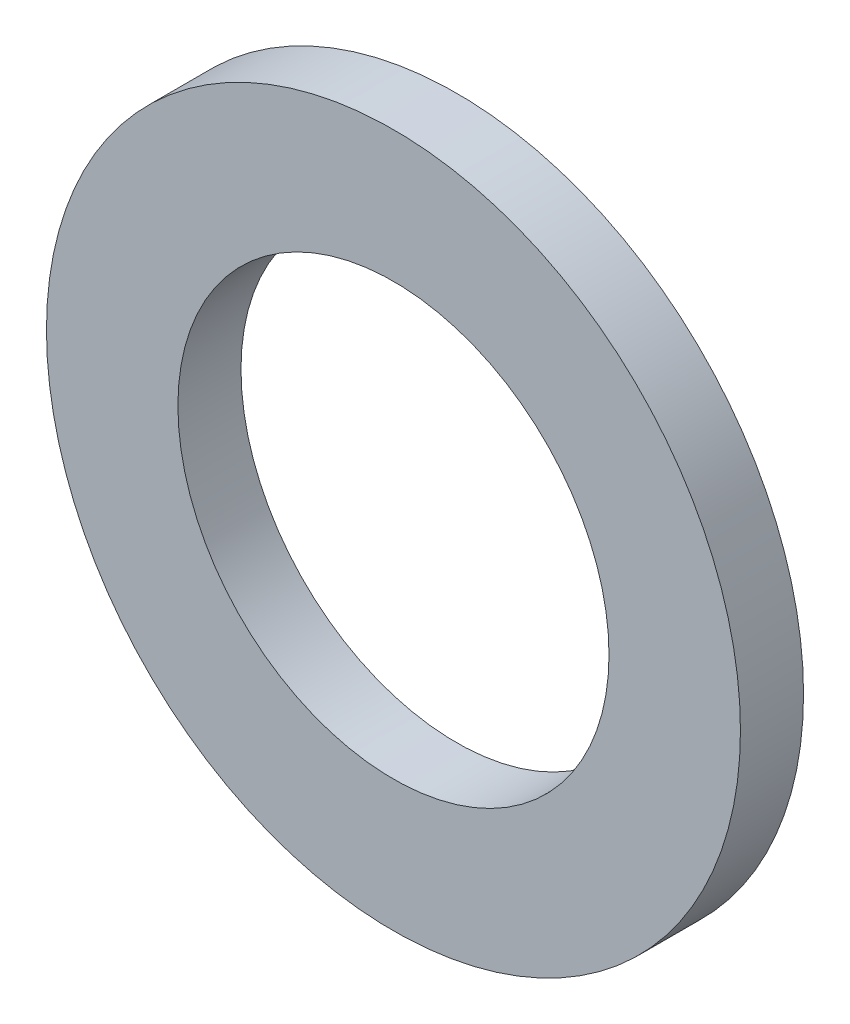
from build123d import *

# Parameters (mm, degrees)
SKETCH_1_R      = 6.6
SKETCH_1_R_2    = 4.1
EXTRUDE_1_DEPTH = 1.2


with BuildPart() as part:
    # Эскиз1 → Бобышка-Вытянуть1 (new body)
    with BuildSketch(Plane.XY):
        Circle(SKETCH_1_R)
        Circle(SKETCH_1_R_2, mode=Mode.SUBTRACT)
    extrude(amount=EXTRUDE_1_DEPTH)


solid = part.part
